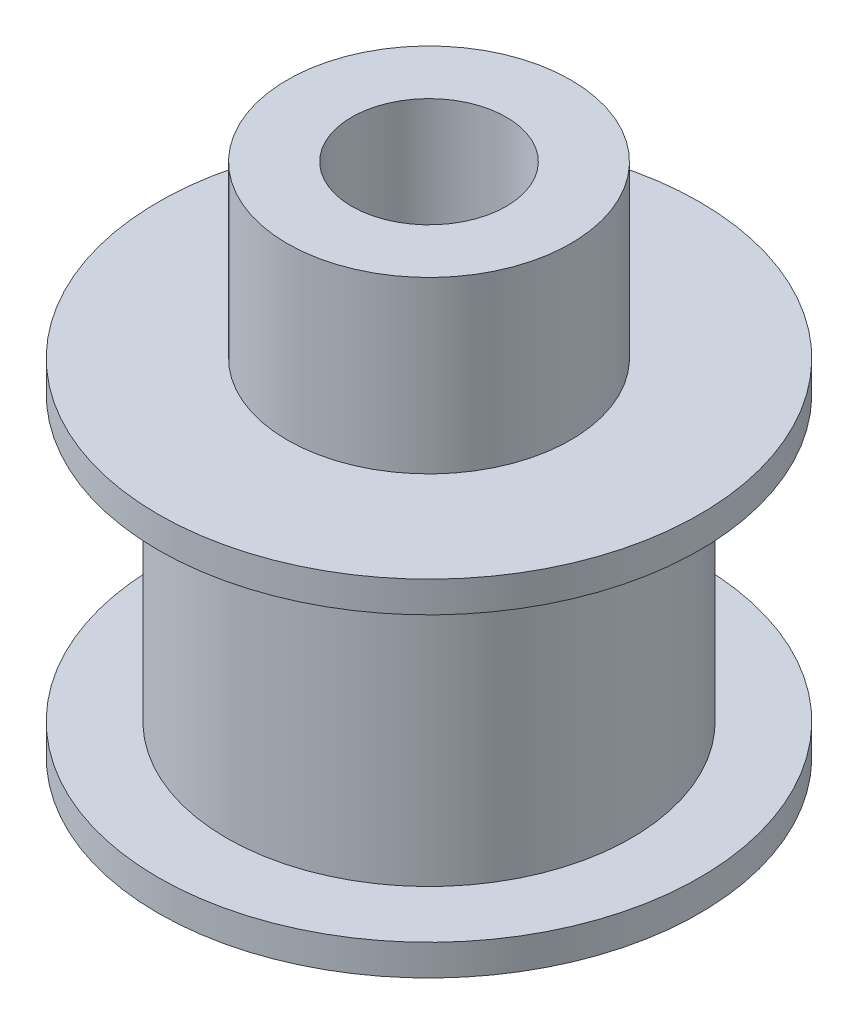
from build123d import *

# Parameters (mm, degrees)
SKETCH1_R           = 10.5
BOSS_EXTRUDE1_DEPTH = 1.2
SKETCH2_R           = 7.85
BOSS_EXTRUDE2_DEPTH = 11
SKETCH3_R           = 10.5
BOSS_EXTRUDE3_DEPTH = 1.2
SKETCH4_R           = 5.5
BOSS_EXTRUDE4_DEPTH = 6.6
SKETCH5_R           = 3
CUT_EXTRUDE1_DEPTH  = 21


with BuildPart() as part:
    # Sketch1 → Boss-Extrude1 (new body)
    with BuildSketch(Plane(origin=(0, 0, 0), x_dir=(1, 0, 0), z_dir=(0, 1, 0))):
        Circle(SKETCH1_R)
    extrude(amount=BOSS_EXTRUDE1_DEPTH)

    # Sketch2 → Boss-Extrude2 (add)
    with BuildSketch(Plane(origin=(0, 1.2, 0), x_dir=(1, 0, 0), z_dir=(0, 1, 0))):
        Circle(SKETCH2_R)
    extrude(amount=BOSS_EXTRUDE2_DEPTH)

    # Sketch3 → Boss-Extrude3 (add)
    with BuildSketch(Plane(origin=(0, 12.2, 0), x_dir=(1, 0, 0), z_dir=(0, 1, 0))):
        Circle(SKETCH3_R)
    extrude(amount=BOSS_EXTRUDE3_DEPTH)

    # Sketch4 → Boss-Extrude4 (add)
    with BuildSketch(Plane(origin=(0, 13.4, 0), x_dir=(1, 0, 0), z_dir=(0, 1, 0))):
        Circle(SKETCH4_R)
    extrude(amount=BOSS_EXTRUDE4_DEPTH)

    # Sketch5 → Cut-Extrude1 (cut, through all)
    with BuildSketch(Plane(origin=(0, 20, 0), x_dir=(1, 0, 0), z_dir=(0, 1, 0))):
        Circle(SKETCH5_R)
    extrude(amount=-CUT_EXTRUDE1_DEPTH, mode=Mode.SUBTRACT)


solid = part.part
